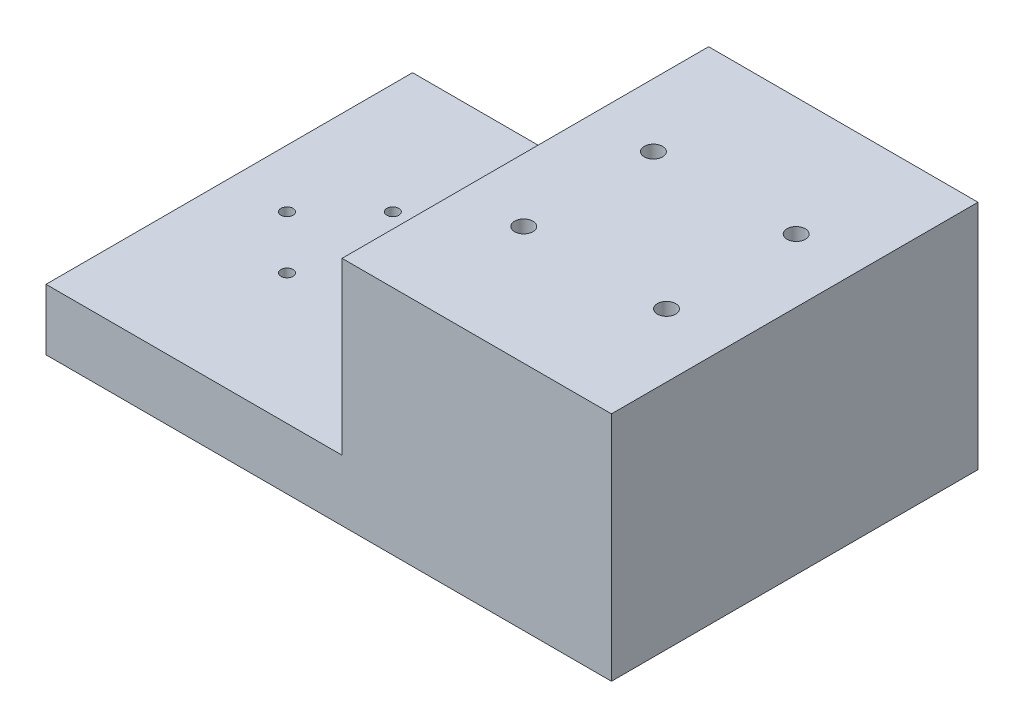
from build123d import *

# Parameters (mm, degrees)
SKETCH1_W                          = 76.2
SKETCH1_H                          = 12.7
BOSS_EXTRUDE1_DEPTH                = 117.55
F_2_5MM_DOWEL_HOLE2_D              = 2.5
SKETCH13_W                         = 56
SKETCH13_H                         = 76.2
BOSS_EXTRUDE3_DEPTH                = 35.45
SKETCH11_R                         = 3.75
CUT_EXTRUDE3_DEPTH                 = 24.5
SKETCH14_R                         = 1.905
CUT_EXTRUDE4_DEPTH                 = 24.65
TAP_DRILL_FOR_M2_5X0_45_TAP1_D     = 2.05
TAP_DRILL_FOR_M2_5X0_45_TAP1_DEPTH = 8.3
TAP_DRILL_FOR_M2_5X0_45_TAP1_TIP   = 0.615882135


with BuildPart() as part:
    # Sketch1 → Boss-Extrude1 (new body)
    with BuildSketch(Plane(origin=(0, 0, 0), x_dir=(0, 0, -1), z_dir=(1, 0, 0))):
        with Locations((0, 6.903854155)):
            Rectangle(SKETCH1_W, SKETCH1_H)
    extrude(amount=BOSS_EXTRUDE1_DEPTH)

    # Ø2.5mm Dowel Hole2 (through all)
    with Locations(Plane(origin=(0, 13.253854155, 0), x_dir=(1, 0, 0), z_dir=(0, 1, 0))):
        with Locations((12, 0), (34, 0), (23, -11), (23, 11)):
            Hole(F_2_5MM_DOWEL_HOLE2_D / 2)

    # Sketch13 → Boss-Extrude3 (add)
    with BuildSketch(Plane(origin=(0, 13.253854155, 0), x_dir=(1, 0, 0), z_dir=(0, 1, 0))):
        with Locations((89.55, 0)):
            Rectangle(SKETCH13_W, SKETCH13_H)
    extrude(amount=BOSS_EXTRUDE3_DEPTH)

    # Sketch11 → Cut-Extrude3 (cut)
    with BuildSketch(Plane(origin=(0, 0.553854155, 0), x_dir=(1, 0, 0), z_dir=(0, 1, 0))):
        with Locations((104.375, 13.4747)):
            Circle(SKETCH11_R)
        with Locations((74.695, 13.4747)):
            Circle(SKETCH11_R)
    cut_extrude3 = extrude(amount=CUT_EXTRUDE3_DEPTH, mode=Mode.SUBTRACT)

    # Sketch14 → Cut-Extrude4 (cut, through all)
    with BuildSketch(Plane.XZ.offset(-25.053854155)):
        with Locations((104.375, -13.4747)):
            Circle(SKETCH14_R)
        with Locations((74.695, -13.4747)):
            Circle(SKETCH14_R)
    cut_extrude4 = extrude(amount=-CUT_EXTRUDE4_DEPTH, mode=Mode.SUBTRACT)

    # Mirror2: Cut-Extrude3, Cut-Extrude4 across plane
    add(cut_extrude3.mirror(Plane.XY), mode=Mode.SUBTRACT)
    add(cut_extrude4.mirror(Plane.XY), mode=Mode.SUBTRACT)

    # Tap Drill for M2.5x0.45 Tap1
    with Locations(Plane.ZY):
        with Locations((-12.7, 6.903854155), (12.7, 6.903854155)):
            Hole(TAP_DRILL_FOR_M2_5X0_45_TAP1_D / 2, depth=TAP_DRILL_FOR_M2_5X0_45_TAP1_DEPTH)
            with Locations((0, 0, -(TAP_DRILL_FOR_M2_5X0_45_TAP1_DEPTH + TAP_DRILL_FOR_M2_5X0_45_TAP1_TIP / 2))):  # 118° drill point
                Cone(0, TAP_DRILL_FOR_M2_5X0_45_TAP1_D / 2, TAP_DRILL_FOR_M2_5X0_45_TAP1_TIP, mode=Mode.SUBTRACT)


solid = part.part
